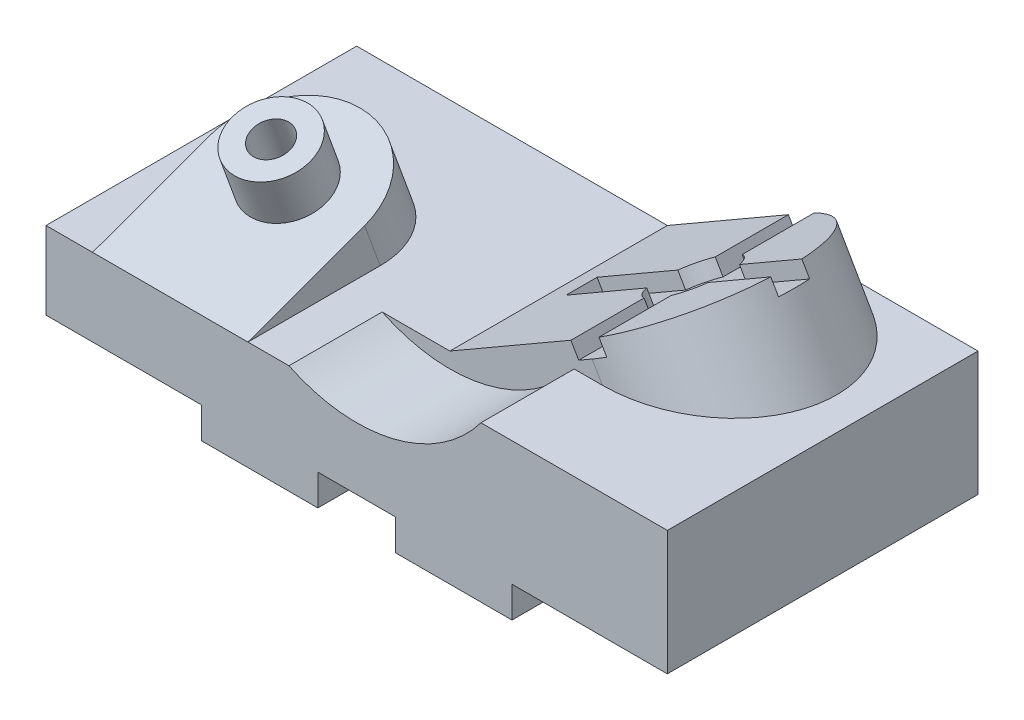
from build123d import *

# Parameters (mm, degrees)
SALIENTE_EXTRUIR1_DEPTH = 50
CORTAR_EXTRUIR1_DEPTH   = 30
SALIENTE_EXTRUIR2_REACH = 69.091
CROQUIS4_R              = 12.5
CROQUIS4_R_2            = 6
SALIENTE_EXTRUIR3_DEPTH = 15
CROQUIS5_R              = 6
CORTAR_EXTRUIR2_DEPTH   = 68.09125606
CORTAR_EXTRUIR3_DEPTH   = 101
SALIENTE_EXTRUIR5_REACH = 82.311
CORTAR_EXTRUIR4_DEPTH   = 5
CROQUIS9_R              = 7.5
CORTAR_EXTRUIR5_DEPTH   = 76.310889132


with BuildPart() as part:
    # Croquis1 → Saliente-Extruir1 (new body, symmetric)
    with BuildSketch(Plane.XY):
        Polygon((0, 0), (0, 25), (100, 25), (100, 40), (200, 40), (200, 0), (150, 0), (150, -10), (112.5, -10), (112.5, 0), (87.5, 0), (87.5, -10), (50, -10), (50, 0), align=None)
    extrude(amount=SALIENTE_EXTRUIR1_DEPTH, both=True)

    # Croquis2 → Cortar-Extruir1 (cut)
    with BuildSketch(Plane.XY.offset(50)):
        with BuildLine():
            Line((78.205505282, 25), (100, 25))
            Line((100, 25), (100, 40))
            Line((100, 40), (140, 40))
            ThreePointArc((140, 40), (111.794494718, 21.411010565), (78.205505282, 25))
        make_face()
    extrude(amount=-CORTAR_EXTRUIR1_DEPTH, mode=Mode.SUBTRACT)

    # Saliente-Extruir2: up to this face of the body (flat: up to its plane)
    saliente_extruir2_end = Plane(part.part.faces().sort_by_distance((47.264467122, 25, -2.448514344))[0])
    # Croquis3 → Saliente-Extruir2 (add, up to the picked face)
    with BuildSketch(Plane(origin=(0, 38.145245781, 13.883734043), x_dir=(-1, 0, 0), z_dir=(0, 0.939692621, 0.342020143)), mode=Mode.PRIVATE) as saliente_extruir2_sk1:
        with BuildLine():
            Line((-15, 38.434127456), (-15, -1.565872544))
            ThreePointArc((-15, -1.565872544), (-40, -26.565872544), (-65, -1.565872544))
            Line((-65, -1.565872544), (-65, 38.434127456))
            Line((-65, 38.434127456), (-15, 38.434127456))
        make_face()
    saliente_extruir2_tool1 = split(extrude(saliente_extruir2_sk1.sketch, amount=-SALIENTE_EXTRUIR2_REACH, mode=Mode.PRIVATE), bisect_by=saliente_extruir2_end, keep=Keep.BOTH, mode=Mode.PRIVATE)
    add(saliente_extruir2_tool1.solids().sort_by(Axis((40, 35.287462, 21.735431), (0, -0.939692621, -0.342020143)))[0])

    # Croquis4 → Saliente-Extruir3 (add)
    with BuildSketch(Plane(origin=(0, 38.145245781, 13.883734043), x_dir=(1, 0, 0), z_dir=(0, 0.939692621, 0.342020143))):
        with Locations(Location((40, 1.565872544, 0), (0, 0, 270))):  # turned: the seam where the file's is
            Circle(CROQUIS4_R)
        with Locations(Location((40, 1.565872544, 0), (0, 0, 270))):  # turned: the seam where the file's is
            Circle(CROQUIS4_R_2, mode=Mode.SUBTRACT)
    extrude(amount=SALIENTE_EXTRUIR3_DEPTH)

    # Croquis5 → Cortar-Extruir2 (cut, through all)
    with BuildSketch(Plane(origin=(0, 38.145245781, 13.883734043), x_dir=(-1, 0, 0), z_dir=(0, 0.939692621, 0.342020143))):
        with Locations(Location((-40, -1.565872544, 0), (0, 0, 90))):  # turned: the seam where the file's is
            Circle(CROQUIS5_R)
    extrude(amount=-CORTAR_EXTRUIR2_DEPTH, mode=Mode.SUBTRACT)

    # Croquis6 → Cortar-Extruir3 (cut, through all)
    with BuildSketch(Plane.XY.offset(50)):
        Polygon((100, 25), (100, 40), (125.980762114, 40), align=None)
    extrude(amount=-CORTAR_EXTRUIR3_DEPTH, mode=Mode.SUBTRACT)

    # Saliente-Extruir5: up to this face of the body (flat: up to its plane)
    saliente_extruir5_end = Plane(part.part.faces().sort_by_distance((164.797670499, 40, -2.108504349))[0])
    # Croquis7 → Saliente-Extruir5 (add, up to the picked face)
    with BuildSketch(Plane(origin=(14.174682453, -24.551270189, 0), x_dir=(0.866025404, 0.5, 0), z_dir=(-0.5, 0.866025404, 0)), mode=Mode.PRIVATE) as saliente_extruir5_sk1:
        with BuildLine():
            Line((99.102540378, 50), (149.102540378, 50))
            ThreePointArc((149.102540378, 50), (184.102540378, 15), (149.102540378, -20))
            Line((149.102540378, -20), (99.102540378, -20))
            Line((99.102540378, -20), (99.102540378, 50))
        make_face()
    saliente_extruir5_tool1 = split(extrude(saliente_extruir5_sk1.sketch, amount=-SALIENTE_EXTRUIR5_REACH, mode=Mode.PRIVATE), bisect_by=saliente_extruir5_end, keep=Keep.BOTH, mode=Mode.PRIVATE)
    add(saliente_extruir5_tool1.solids().sort_by(Axis((133.894705, 44.569117, -15), (0.5, -0.866025404, 0)))[0])

    # Croquis8 → Cortar-Extruir4 (cut)
    with BuildSketch(Plane(origin=(14.174682453, -24.551270189, 0), x_dir=(0.866025404, 0.5, 0), z_dir=(-0.5, 0.866025404, 0))):
        with BuildLine():
            Line((154.102540378, 3.543560763), (154.102540378, -26.456439237))
            Line((154.102540378, -26.456439237), (144.102540378, -26.456439237))
            Line((144.102540378, -26.456439237), (144.102540378, 3.543560763))
            ThreePointArc((144.102540378, 3.543560763), (140.263705614, 6.161165235), (137.646101141, 10))
            Line((137.646101141, 10), (107.646101141, 10))
            Line((107.646101141, 10), (107.646101141, 20))
            Line((107.646101141, 20), (137.646101141, 20))
            ThreePointArc((137.646101141, 20), (140.263705614, 23.838834765), (144.102540378, 26.456439237))
            Line((144.102540378, 26.456439237), (144.102540378, 56.456439237))
            Line((144.102540378, 56.456439237), (154.102540378, 56.456439237))
            Line((154.102540378, 56.456439237), (154.102540378, 26.456439237))
            ThreePointArc((154.102540378, 26.456439237), (157.941375143, 23.838834765), (160.558979616, 20))
            Line((160.558979616, 20), (190.558979616, 20))
            Line((190.558979616, 20), (190.558979616, 10))
            Line((190.558979616, 10), (160.558979616, 10))
            ThreePointArc((160.558979616, 10), (157.941375143, 6.161165235), (154.102540378, 3.543560763))
        make_face()
    extrude(amount=-CORTAR_EXTRUIR4_DEPTH, mode=Mode.SUBTRACT)

    # Croquis9 → Cortar-Extruir5 (cut, through all)
    with BuildSketch(Plane(origin=(16.674682453, -28.881397208, 0), x_dir=(0.866025404, 0.5, 0), z_dir=(-0.5, 0.866025404, 0))):
        with Locations(Location((149.102540378, 15, 0), (0, 0, 180))):  # turned: the seam where the file's is
            Circle(CROQUIS9_R)
    extrude(amount=-CORTAR_EXTRUIR5_DEPTH, mode=Mode.SUBTRACT)


solid = part.part
